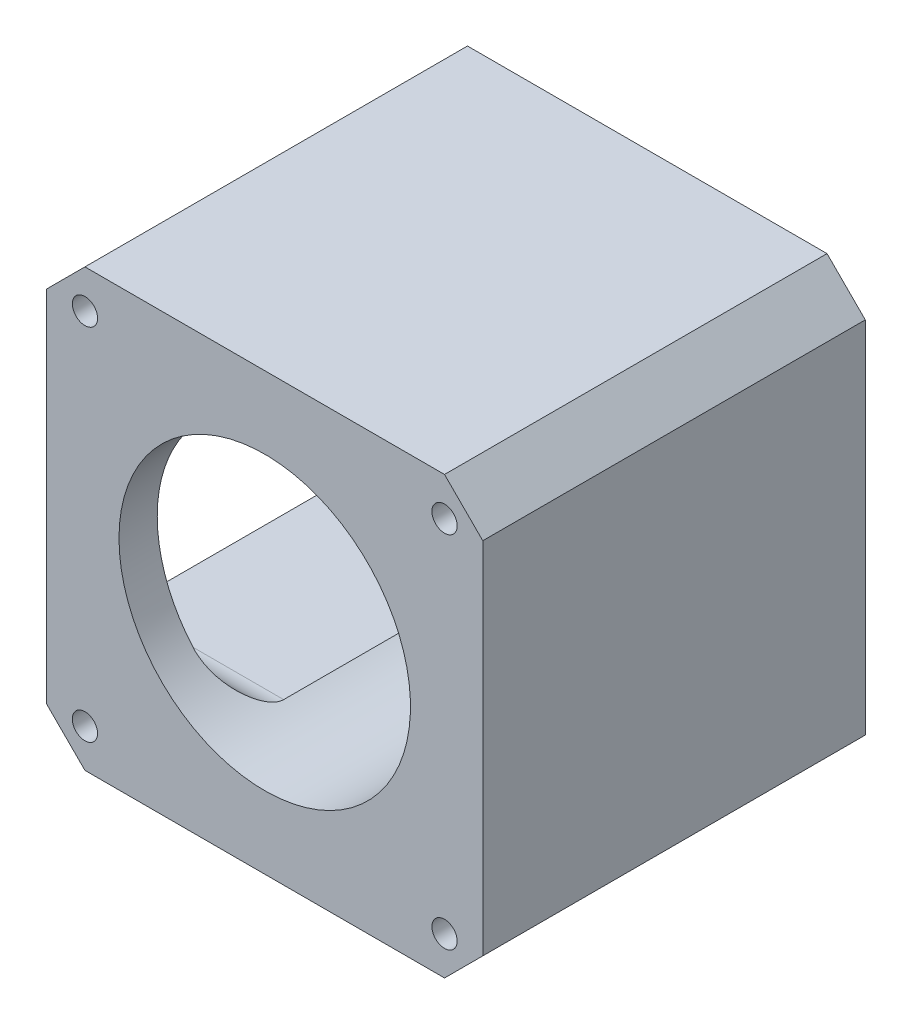
from build123d import *

# Parameters (mm, degrees)
SKETCH_1_W             = 57
SKETCH_1_H             = 57
EXTRUDE_1_DEPTH        = 25
SKETCH_2_R             = 19.05
CUT_EXTRUDE_1_DEPTH    = 51
SKETCH_3_W             = 40
SKETCH_3_H             = 35
CUT_EXTRUDE_2_DEPTH    = 32
CHAMFER_1_SIZE         = 5
HOLE_WIZARD_M4_1_D     = 3.3
HOLE_WIZARD_M4_1_DEPTH = 18.5
HOLE_WIZARD_M4_1_TIP   = 0.991420021
FILLET_1_R             = 5
HOLE_WIZARD_M3_1_D     = 2.5
HOLE_WIZARD_M3_1_DEPTH = 10
HOLE_WIZARD_M3_1_TIP   = 0.751075774
HOLE_WIZARD_M4_2_D     = 3.3
HOLE_WIZARD_M4_2_DEPTH = 18.5
HOLE_WIZARD_M4_2_TIP   = 0.991420021


with BuildPart() as part:
    # 草图1 → 凸台-拉伸1 (new body, symmetric)
    with BuildSketch(Plane.XY):
        Rectangle(SKETCH_1_W, SKETCH_1_H)
    extrude(amount=EXTRUDE_1_DEPTH, both=True)

    # 草图2 → 切除-拉伸1 (cut, through all)
    with BuildSketch(Plane(origin=(0, 0, -25), x_dir=(-1, 0, 0), z_dir=(0, 0, -1))):
        Circle(SKETCH_2_R)
    extrude(amount=-CUT_EXTRUDE_1_DEPTH, mode=Mode.SUBTRACT)

    # 草图3 → 切除-拉伸2 (cut)
    with BuildSketch(Plane(origin=(-28.5, 0, 0), x_dir=(0, 0, -1), z_dir=(1, 0, 0))):
        Rectangle(SKETCH_3_W, SKETCH_3_H)
    extrude(amount=CUT_EXTRUDE_2_DEPTH, mode=Mode.SUBTRACT)

    # 倒角1
    chamfer_1_edges = [part.edges().sort_by_distance(p)[0] for p in [
        (28.5, -28.5, 0),
        (-28.5, -28.5, 0),
        (-28.5, 28.5, 0),
        (28.5, 28.5, 0),
    ]]
    chamfer(chamfer_1_edges, length=CHAMFER_1_SIZE)

    # M4 螺纹孔1
    with Locations(Plane(origin=(0, 0, -25), x_dir=(-1, 0, 0), z_dir=(0, 0, -1))):
        with Locations((-23.5, 23.5), (23.5, 23.5), (23.5, -23.5), (-23.5, -23.5)):
            Hole(HOLE_WIZARD_M4_1_D / 2, depth=HOLE_WIZARD_M4_1_DEPTH)
            with Locations((0, 0, -(HOLE_WIZARD_M4_1_DEPTH + HOLE_WIZARD_M4_1_TIP / 2))):  # 118° drill point
                Cone(0, HOLE_WIZARD_M4_1_D / 2, HOLE_WIZARD_M4_1_TIP, mode=Mode.SUBTRACT)

    # 圆角1
    fillet_1_edges = [part.edges().sort_by_distance(p)[0] for p in [
        (-18.013392751, -17.5, -20),
        (-18.013392751, 17.5, -20),
        (-18.013392751, 17.5, 20),
        (-18.013392751, -17.5, 20),
    ]]
    fillet(fillet_1_edges, radius=FILLET_1_R)

    # M3 螺纹孔1
    with Locations(Plane.ZY.offset(28.5)):
        with Locations((21, 19), (-21, 19), (-21, -19), (21, -19)):
            Hole(HOLE_WIZARD_M3_1_D / 2, depth=HOLE_WIZARD_M3_1_DEPTH)
            with Locations((0, 0, -(HOLE_WIZARD_M3_1_DEPTH + HOLE_WIZARD_M3_1_TIP / 2))):  # 118° drill point
                Cone(0, HOLE_WIZARD_M3_1_D / 2, HOLE_WIZARD_M3_1_TIP, mode=Mode.SUBTRACT)

    # M4 螺纹孔2
    with Locations(Plane.XY.offset(25)):
        with Locations((23.5, 23.5), (-23.5, 23.5), (-23.5, -23.5), (23.5, -23.5)):
            Hole(HOLE_WIZARD_M4_2_D / 2, depth=HOLE_WIZARD_M4_2_DEPTH)
            with Locations((0, 0, -(HOLE_WIZARD_M4_2_DEPTH + HOLE_WIZARD_M4_2_TIP / 2))):  # 118° drill point
                Cone(0, HOLE_WIZARD_M4_2_D / 2, HOLE_WIZARD_M4_2_TIP, mode=Mode.SUBTRACT)


solid = part.part
